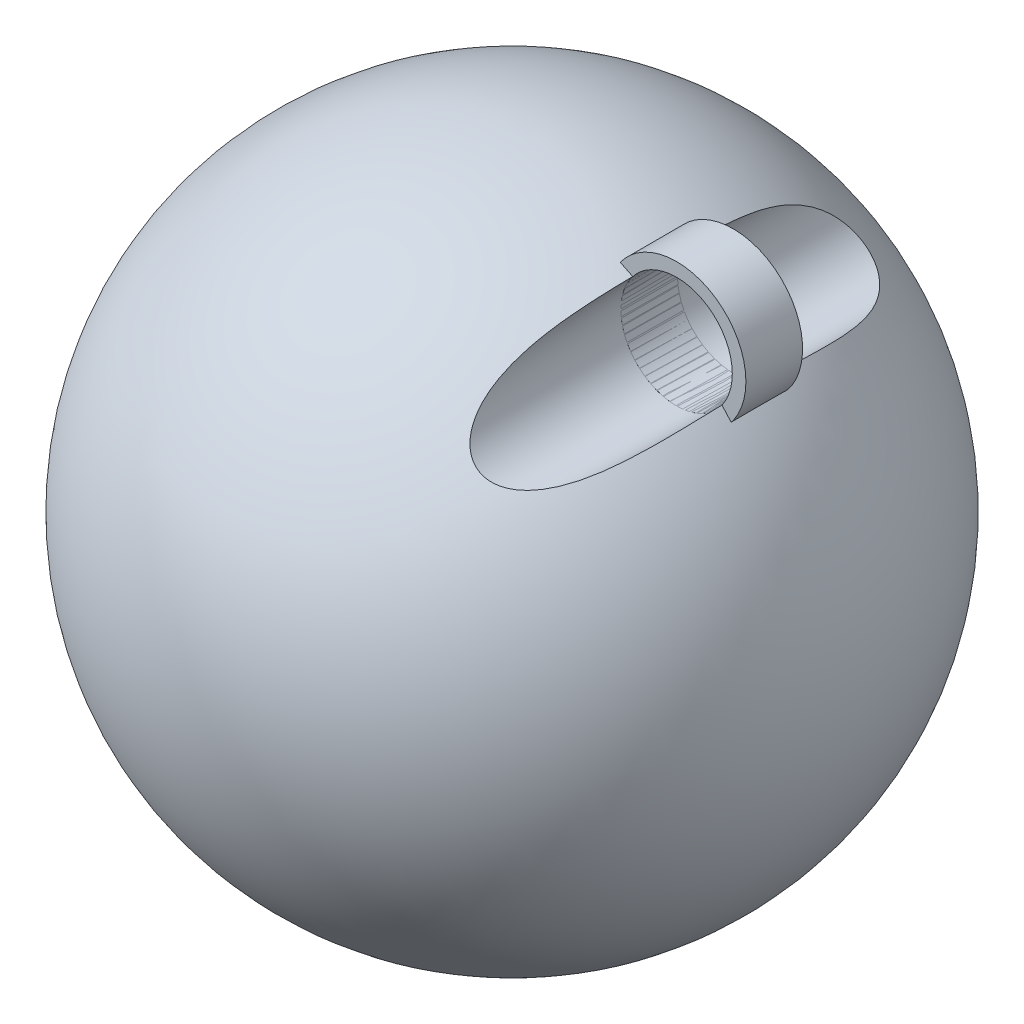
from build123d import *

# Parameters (mm, degrees)
AUFSATZ_LINEAR_AUSTRAGEN1_DEPTH = 25
SKIZZE5_R                       = 49.148822587
SCHNITT_LINEAR_AUSTRAGEN3_DEPTH = 200


with BuildPart() as part:
    # Skizze1 → Rotation1 (revolve)
    with BuildSketch(Plane.XY):
        with BuildLine():
            Line((0, -100.057658787), (0, -681.525107773))
            ThreePointArc((0, -681.525107773), (290.733724493, -390.79138328), (0, -100.057658787))
        make_face()
    revolve(axis=Axis((0, -100.057658787, 0), (0, -1, 0)))

    # Skizze5 → Schnitt-Linear austragen3 (cut, symmetric)
    with BuildSketch(Plane.XY):
        with Locations(Location((170.114345328, -163.08975929, 0), (0, 0, 180))):  # turned: the seam where the file's is
            Circle(SKIZZE5_R)
    extrude(amount=SCHNITT_LINEAR_AUSTRAGEN3_DEPTH, both=True, mode=Mode.SUBTRACT)


with BuildPart() as body_2:
    # Skizze2 → Aufsatz-Linear austragen1 (new body, symmetric)
    with BuildSketch(Plane.XY):
        with BuildLine():
            ThreePointArc((121.127022973, -126.491661631), (206.712442986, -114.102436935), (219.101667683, -199.687856948))
            ThreePointArc((219.101667683, -199.687856948), (133.516247669, -212.077081645), (121.127022973, -126.491661631))
        make_face()
        with BuildLine():
            ThreePointArc((130.74041933, -133.673765118), (199.5303395, -123.715833291), (209.488271326, -192.505753462))
            ThreePointArc((209.488271326, -192.505753462), (140.698351156, -202.463685288), (130.74041933, -133.673765118))
        make_face(mode=Mode.SUBTRACT)
    extrude(amount=AUFSATZ_LINEAR_AUSTRAGEN1_DEPTH, both=True)


solid = Compound([part.part, body_2.part])
